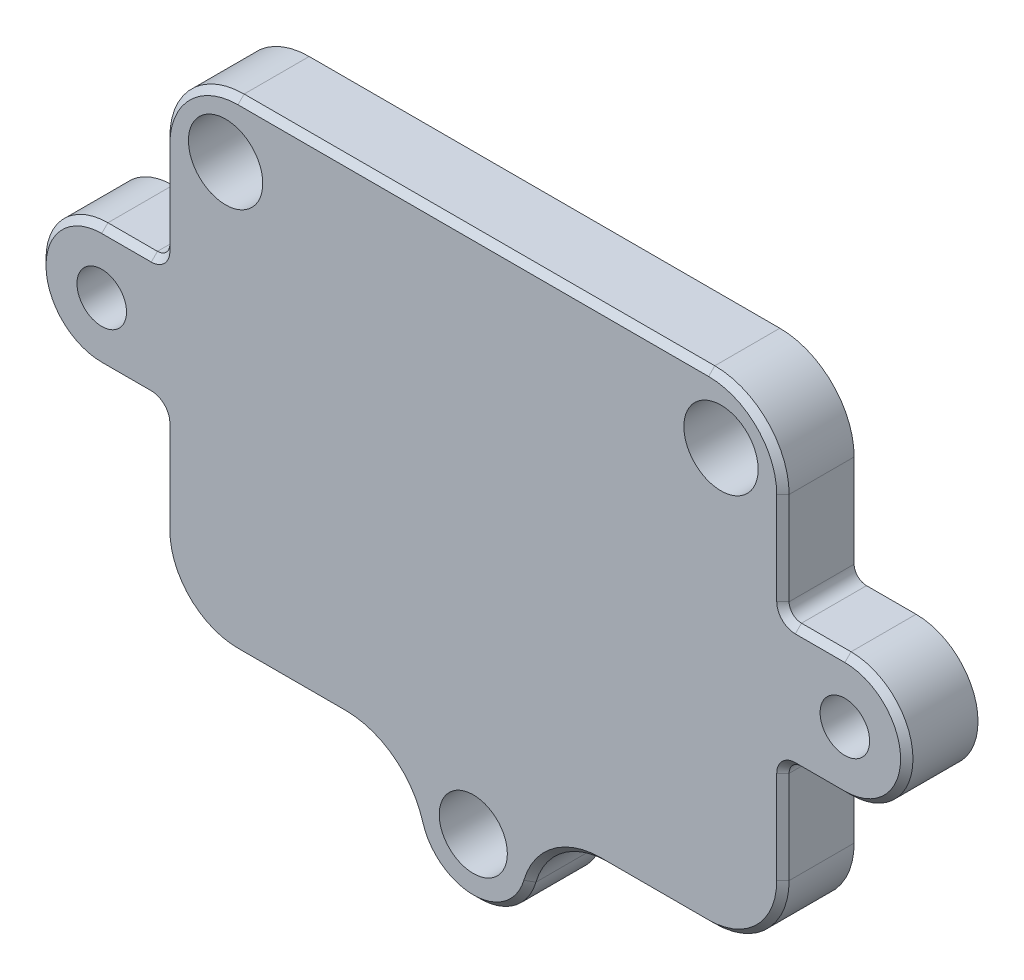
from build123d import *

# Parameters (mm, degrees)
SKETCH1_R           = 3
SKETCH1_R_2         = 2
SKETCH1_R_3         = 2.75
BOSS_EXTRUDE1_DEPTH = 5.75
CHAMFER1_SIZE       = 0.5


with BuildPart() as part:
    # Sketch1 → Boss-Extrude1 (new body)
    with BuildSketch(Plane.XY):
        with BuildLine():
            Line((19, 0), (-19, 0))
            ThreePointArc((-19, 0), (-23.242640687, -1.757359313), (-25, -6))
            Line((-25, -6), (-25, -13.5))
            ThreePointArc((-25, -13.5), (-25.292893219, -14.207106781), (-26, -14.5))
            Line((-26, -14.5), (-30, -14.5))
            ThreePointArc((-30, -14.5), (-35, -19.5), (-30, -24.5))
            Line((-30, -24.5), (-26, -24.5))
            ThreePointArc((-26, -24.5), (-25.292893219, -24.792893219), (-25, -25.5))
            Line((-25, -25.5), (-25, -33))
            ThreePointArc((-25, -33), (-23.242640687, -37.242640687), (-19, -39))
            Line((-19, -39), (-10.322911411, -39))
            ThreePointArc((-10.322911411, -39), (-6.72058658, -40.201744503), (-4.561286437, -43.325581395))
            ThreePointArc((-4.561286437, -43.325581395), (0, -46.75), (4.561286437, -43.325581395))
            ThreePointArc((4.561286437, -43.325581395), (6.72058658, -40.201744503), (10.322911411, -39))
            Line((10.322911411, -39), (19, -39))
            ThreePointArc((19, -39), (23.242640687, -37.242640687), (25, -33))
            Line((25, -33), (25, -25.5))
            ThreePointArc((25, -25.5), (25.292893219, -24.792893219), (26, -24.5))
            Line((26, -24.5), (30, -24.5))
            ThreePointArc((30, -24.5), (35, -19.5), (30, -14.5))
            Line((30, -14.5), (26, -14.5))
            ThreePointArc((26, -14.5), (25.292893219, -14.207106781), (25, -13.5))
            Line((25, -13.5), (25, -6))
            ThreePointArc((25, -6), (23.242640687, -1.757359313), (19, 0))
        make_face()
        with Locations((20, -5)):
            Circle(SKETCH1_R, mode=Mode.SUBTRACT)
        with Locations((30, -19.5)):
            Circle(SKETCH1_R_2, mode=Mode.SUBTRACT)
        with Locations((-30, -19.5)):
            Circle(SKETCH1_R_2, mode=Mode.SUBTRACT)
        with Locations((0, -42)):
            Circle(SKETCH1_R_3, mode=Mode.SUBTRACT)
        with Locations((-20, -5)):
            Circle(SKETCH1_R, mode=Mode.SUBTRACT)
    extrude(amount=BOSS_EXTRUDE1_DEPTH)

    # Chamfer1
    chamfer1_edges = [part.edges().sort_by_distance(p)[0] for p in [
        (35, -19.5, 5.75),
        (28, -14.5, 5.75),
        (25.292893219, -14.207106781, 5.75),
        (25, -9.75, 5.75),
        (23.242640687, -1.757359313, 5.75),
        (0, 0, 5.75),
        (-23.242640687, -1.757359313, 5.75),
        (-25, -9.75, 5.75),
        (-25.292893219, -14.207106781, 5.75),
        (-28, -14.5, 5.75),
        (-35, -19.5, 5.75),
        (-28, -24.5, 5.75),
        (-25.292893219, -24.792893219, 5.75),
        (-25, -29.25, 5.75),
        (-23.242640687, -37.242640687, 5.75),
        (-14.661455706, -39, 5.75),
        (-6.72058658, -40.201744503, 5.75),
        (0, -46.75, 5.75),
        (6.72058658, -40.201744503, 5.75),
        (14.661455706, -39, 5.75),
        (23.242640687, -37.242640687, 5.75),
        (25, -29.25, 5.75),
        (25.292893219, -24.792893219, 5.75),
        (28, -24.5, 5.75),
    ]]
    chamfer(chamfer1_edges, length=CHAMFER1_SIZE)


solid = part.part
